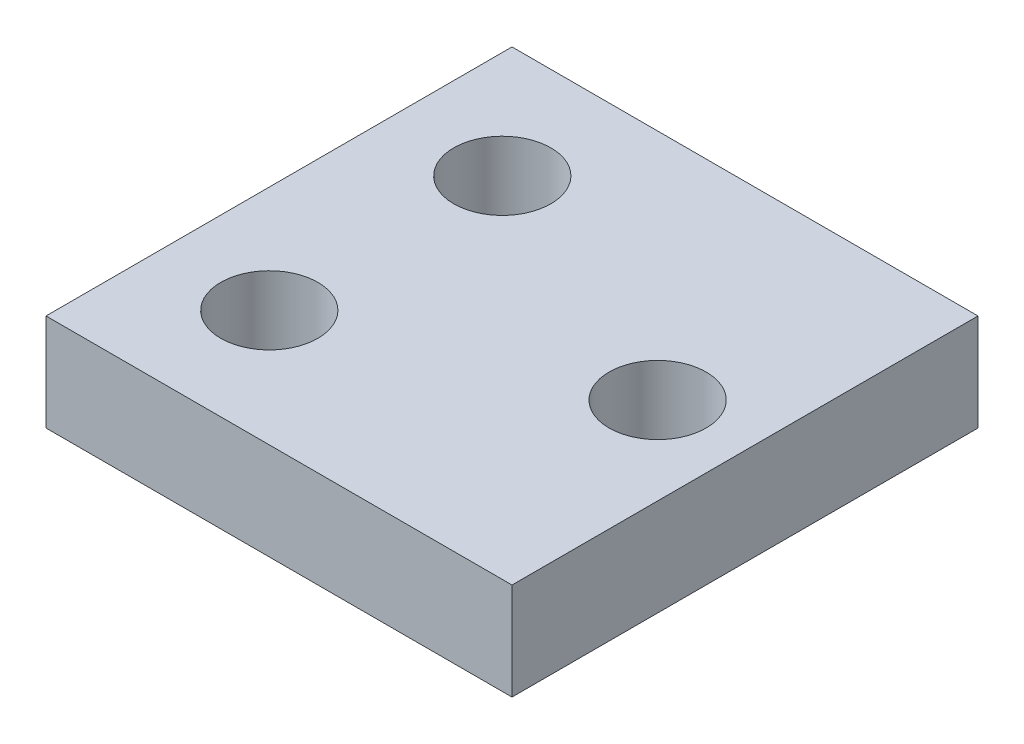
from build123d import *

# Parameters (mm, degrees)
SKETCH1_W           = 30.48
SKETCH1_H           = 30.48
BOSS_EXTRUDE1_DEPTH = 3.175
CUT_EXTRUDE1_REACH  = 8.35
SKETCH2_R           = 3.175


with BuildPart() as part:
    # Sketch1 → Boss-Extrude1 (new body, symmetric)
    with BuildSketch(Plane(origin=(0, 0, 0), x_dir=(1, 0, 0), z_dir=(0, 1, 0))):
        Rectangle(SKETCH1_W, SKETCH1_H)
    extrude(amount=BOSS_EXTRUDE1_DEPTH, both=True)

    # Sketch2 → Cut-Extrude1 (cut, up to next)
    with BuildSketch(Plane(origin=(0, 3.175, 0), x_dir=(1, 0, 0), z_dir=(0, 1, 0)), mode=Mode.PRIVATE) as cut_extrude1_sk1:
        with Locations((9.525, 0)):
            Circle(SKETCH2_R)
    cut_extrude1_tool1 = extrude(cut_extrude1_sk1.sketch, amount=-CUT_EXTRUDE1_REACH, mode=Mode.PRIVATE) & part.part
    add(cut_extrude1_tool1.solids().sort_by_distance((9.525, 3.175, 0))[0], mode=Mode.SUBTRACT)
    # Sketch2 → Cut-Extrude1 (cut, up to next)
    with BuildSketch(Plane(origin=(0, 3.175, 0), x_dir=(1, 0, 0), z_dir=(0, 1, 0)), mode=Mode.PRIVATE) as cut_extrude1_sk2:
        with Locations((-8.255, -7.62)):
            Circle(SKETCH2_R)
    cut_extrude1_tool2 = extrude(cut_extrude1_sk2.sketch, amount=-CUT_EXTRUDE1_REACH, mode=Mode.PRIVATE) & part.part
    add(cut_extrude1_tool2.solids().sort_by_distance((-8.255, 3.175, 7.62))[0], mode=Mode.SUBTRACT)
    # Sketch2 → Cut-Extrude1 (cut, up to next)
    with BuildSketch(Plane(origin=(0, 3.175, 0), x_dir=(1, 0, 0), z_dir=(0, 1, 0)), mode=Mode.PRIVATE) as cut_extrude1_sk3:
        with Locations((-8.255, 7.62)):
            Circle(SKETCH2_R)
    cut_extrude1_tool3 = extrude(cut_extrude1_sk3.sketch, amount=-CUT_EXTRUDE1_REACH, mode=Mode.PRIVATE) & part.part
    add(cut_extrude1_tool3.solids().sort_by_distance((-8.255, 3.175, -7.62))[0], mode=Mode.SUBTRACT)


solid = part.part
